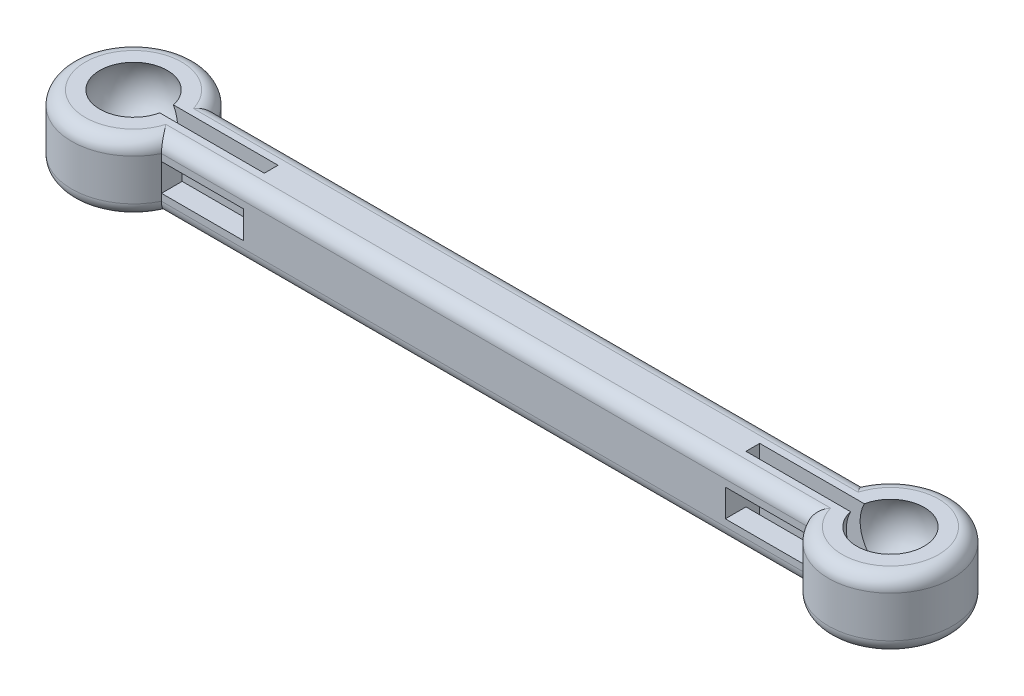
from build123d import *

# Parameters (mm, degrees)
BOSS_EXTRUDE1_DEPTH = 5
CUT_EXTRUDE1_REACH  = 34.699
CUT_EXTRUDE2_REACH  = 35.034
FILLET1_R           = 1
FILLET2_R           = 1


with BuildPart() as part:
    # Sketch1 → Boss-Extrude1 (new body)
    with BuildSketch(Plane(origin=(0, 0, 0), x_dir=(1, 0, 0), z_dir=(0, 1, 0))):
        with BuildLine():
            Line((-27.5, 2), (-27.5, -2))
            Line((-27.5, -2), (-23.46887112585063, -2))
            ThreePointArc((-23.468871125850672, -1.9999999999998734), (-23.11878556027716, -1.0271124734730797), (-23.000000000000007, -1.1e-15))
            ThreePointArc((-23.000000000000007, 0), (-23.11878556027716, 1.0271124734730805), (-23.468871125850672, 1.9999999999998725))
            Line((-23.46887112585063, 2), (-27.5, 2))
        make_face()
        with BuildLine():
            Line((-23.46887112585063, -2), (-27.5, -2))
            Line((-27.5, -2), (-27.5, 2))
            Line((-27.5, 2), (-23.46887112585063, 2))
            ThreePointArc((-23.468871125850672, 1.9999999999998725), (-31.999999999999993, 5.5e-16), (-23.468871125850672, -1.9999999999998734))
        make_face()
        with BuildLine():
            ThreePointArc((-23.000000000000007, -1.1e-15), (-23.11878556027716, -1.0271124734730797), (-23.468871125850672, -1.9999999999998734))
            Line((-23.46887112585063, -2), (23.46887112585071, -2))
            ThreePointArc((23.46887112585072, -1.9999999999999738), (23.000000000000007, 5.5e-16), (23.46887112585072, 1.9999999999999747))
            Line((23.46887112585071, 2), (-23.46887112585063, 2))
            ThreePointArc((-23.468871125850672, 1.9999999999998725), (-23.11878556027716, 1.0271124734730805), (-23.000000000000007, 0))
        make_face()
        with BuildLine():
            ThreePointArc((23.46887112585072, 1.9999999999999747), (23.000000000000007, 5.5e-16), (23.46887112585072, -1.9999999999999738))
            Line((23.46887112585071, -2), (27.5, -2))
            Line((27.5, -2), (27.5, 2))
            Line((27.5, 2), (23.46887112585071, 2))
        make_face()
        with BuildLine():
            Line((27.5, -2), (23.46887112585071, -2))
            ThreePointArc((23.46887112585072, -1.9999999999999738), (28.52711247347313, -4.381214439722833), (31.999999999999993, -1.1e-15))
            ThreePointArc((31.999999999999993, 0), (28.527112473473135, 4.381214439722831), (23.46887112585072, 1.9999999999999747))
            Line((23.46887112585071, 2), (27.5, 2))
            Line((27.5, 2), (27.5, -2))
        make_face()
    extrude(amount=BOSS_EXTRUDE1_DEPTH)

    # Cut-Sweep1: sweep along a path in Sketch2
    with BuildLine(Plane(origin=(0, 5, 0), x_dir=(1, 0, 0), z_dir=(0, 1, 0))) as cut_sweep1_path:
        CenterArc((-27.5, 0), 4.499999999999991, 0, 360)
    # 3DSketch1 → Cut-Sweep1 (sweep, cut)
    with BuildSketch(Plane(origin=(-27.5, 5, 0), x_dir=(0, -1, 0), z_dir=(-1, 0, 0))):
        with BuildLine():
            Line((0, 0), (-1.5000000000000004, 0))
            ThreePointArc((-1.5000000000000004, 0), (1.25, 2.75), (4, 0))
            Line((4, 0), (0, 0))
        make_face()
    cut_sweep1 = sweep(path=cut_sweep1_path.line, mode=Mode.SUBTRACT)

    # Mirror1: Cut-Sweep1 across plane
    add(cut_sweep1.mirror(Plane(origin=(0, 0, 0), x_dir=(0, 0, 1), z_dir=(1, 0, 0))), mode=Mode.SUBTRACT)

    # Cut-Extrude1: up to this face of the body (flat: up to its plane)
    cut_extrude1_end = Plane(part.part.faces().sort_by_distance((0, 5, -1.972e-06))[0])
    # Sketch3 → Cut-Extrude1 (cut, up to the picked face)
    with BuildSketch(Plane.XZ, mode=Mode.PRIVATE) as cut_extrude1_sk1:
        with BuildLine():
            ThreePointArc((-23.027864045000427, 0.49999999999997785), (-23.006971411314083, 0.2503879015666308), (-23.000000000000007, 0))
            Line((-23.000000000000007, 0), (-17.5, 0))
            Line((-17.5, 0), (-17.5, 0.5))
            Line((-17.5, 0.5), (-23.027864045000424, 0.5))
        make_face()
    cut_extrude1_tool1 = split(extrude(cut_extrude1_sk1.sketch, amount=-CUT_EXTRUDE1_REACH, mode=Mode.PRIVATE), bisect_by=cut_extrude1_end, keep=Keep.BOTH, mode=Mode.PRIVATE)
    # Sketch3 → Cut-Extrude1 (cut, up to the picked face)
    with BuildSketch(Plane.XZ, mode=Mode.PRIVATE) as cut_extrude1_sk2:
        with BuildLine():
            Line((-17.5, 0), (-23.000000000000007, 0))
            ThreePointArc((-23.000000000000007, -1.1e-15), (-23.006971411314083, -0.25038790156662954), (-23.027864045000427, -0.49999999999997824))
            Line((-23.027864045000424, -0.5), (-17.5, -0.5))
            Line((-17.5, -0.5), (-17.5, 0))
        make_face()
    cut_extrude1_tool2 = split(extrude(cut_extrude1_sk2.sketch, amount=-CUT_EXTRUDE1_REACH, mode=Mode.PRIVATE), bisect_by=cut_extrude1_end, keep=Keep.BOTH, mode=Mode.PRIVATE)
    # Sketch3 → Cut-Extrude1 (cut, up to the picked face)
    with BuildSketch(Plane.XZ, mode=Mode.PRIVATE) as cut_extrude1_sk3:
        with BuildLine():
            Line((-27.5, 0.5), (-27.5, 0))
            Line((-27.5, 0), (-23.000000000000007, 0))
            ThreePointArc((-23.000000000000007, 0), (-23.006971411314083, 0.2503879015666308), (-23.027864045000427, 0.49999999999997785))
            Line((-23.027864045000424, 0.5), (-27.5, 0.5))
        make_face()
    cut_extrude1_tool3 = split(extrude(cut_extrude1_sk3.sketch, amount=-CUT_EXTRUDE1_REACH, mode=Mode.PRIVATE), bisect_by=cut_extrude1_end, keep=Keep.BOTH, mode=Mode.PRIVATE)
    # Sketch3 → Cut-Extrude1 (cut, up to the picked face)
    with BuildSketch(Plane.XZ, mode=Mode.PRIVATE) as cut_extrude1_sk4:
        with BuildLine():
            Line((-23.000000000000007, 0), (-27.5, 0))
            Line((-27.5, 0), (-27.5, -0.5))
            Line((-27.5, -0.5), (-23.027864045000424, -0.5))
            ThreePointArc((-23.027864045000427, -0.49999999999997824), (-23.006971411314083, -0.25038790156662954), (-23.000000000000007, -1.1e-15))
        make_face()
    cut_extrude1_tool4 = split(extrude(cut_extrude1_sk4.sketch, amount=-CUT_EXTRUDE1_REACH, mode=Mode.PRIVATE), bisect_by=cut_extrude1_end, keep=Keep.BOTH, mode=Mode.PRIVATE)
    cut_extrude1_1 = cut_extrude1_tool1.solids().sort_by(Axis((-20.254644, 0, 0.250211), (0, 1, 0)))[0]
    add(cut_extrude1_1, mode=Mode.SUBTRACT)
    cut_extrude1_2 = cut_extrude1_tool2.solids().sort_by(Axis((-20.254644, 0, -0.250211), (0, 1, 0)))[0]
    add(cut_extrude1_2, mode=Mode.SUBTRACT)
    cut_extrude1_3 = cut_extrude1_tool3.solids().sort_by(Axis((-25.254631, 0, 0.249742), (0, 1, 0)))[0]
    add(cut_extrude1_3, mode=Mode.SUBTRACT)
    cut_extrude1_4 = cut_extrude1_tool4.solids().sort_by(Axis((-25.254631, 0, -0.249742), (0, 1, 0)))[0]
    add(cut_extrude1_4, mode=Mode.SUBTRACT)
    cut_extrude1 = cut_extrude1_1 + cut_extrude1_2 + cut_extrude1_3 + cut_extrude1_4  # Cut-Extrude1 as one shape, for the pattern or mirror that repeats it

    # Mirror2: Cut-Extrude1 across plane
    add(cut_extrude1.mirror(Plane(origin=(0, 0, 0), x_dir=(0, 0, 1), z_dir=(1, 0, 0))), mode=Mode.SUBTRACT)

    # Cut-Extrude2: up to this face of the body (flat: up to its plane)
    cut_extrude2_end = Plane(part.part.faces().sort_by_distance((0, 2.5, 2))[0])
    # Sketch4 → Cut-Extrude2 (cut, up to the picked face)
    with BuildSketch(Plane(origin=(0, 0, -2), x_dir=(-1, 0, 0), z_dir=(0, 0, -1)), mode=Mode.PRIVATE) as cut_extrude2_sk1:
        Polygon((17.499999999999996, 1.5000000000000016), (21.678209788095515, 1.5000000000000016), (19.290661337755218, 3.500000000000003), (17.499999999999996, 3.5000000000000018), align=None)
    cut_extrude2_tool1 = split(extrude(cut_extrude2_sk1.sketch, amount=-CUT_EXTRUDE2_REACH, mode=Mode.PRIVATE), bisect_by=cut_extrude2_end, keep=Keep.BOTH, mode=Mode.PRIVATE)
    # Sketch4 → Cut-Extrude2 (cut, up to the picked face)
    with BuildSketch(Plane(origin=(0, 0, -2), x_dir=(-1, 0, 0), z_dir=(0, 0, -1)), mode=Mode.PRIVATE) as cut_extrude2_sk2:
        Polygon((19.290661337755218, 3.500000000000003), (21.678209788095515, 1.5000000000000009), (23.468871125850736, 1.5000000000000016), (23.468871125850736, 3.5000000000000018), align=None)
    cut_extrude2_tool2 = split(extrude(cut_extrude2_sk2.sketch, amount=-CUT_EXTRUDE2_REACH, mode=Mode.PRIVATE), bisect_by=cut_extrude2_end, keep=Keep.BOTH, mode=Mode.PRIVATE)
    cut_extrude2_1 = cut_extrude2_tool1.solids().sort_by(Axis((-19.071803, 2.366667, -2), (0, 0, 1)))[0]
    add(cut_extrude2_1, mode=Mode.SUBTRACT)
    cut_extrude2_2 = cut_extrude2_tool2.solids().sort_by(Axis((-21.897068, 2.633333, -2), (0, 0, 1)))[0]
    add(cut_extrude2_2, mode=Mode.SUBTRACT)
    cut_extrude2 = cut_extrude2_1 + cut_extrude2_2  # Cut-Extrude2 as one shape, for the pattern or mirror that repeats it

    # Mirror3: Cut-Extrude2 across plane
    add(cut_extrude2.mirror(Plane(origin=(0, 0, 0), x_dir=(0, 0, 1), z_dir=(1, 0, 0))), mode=Mode.SUBTRACT)

    # Fillet1
    fillet1_edges = [part.edges().sort_by_distance(p)[0] for p in [
        (2.842e-14, 5, 1.9999999999999656),
        (31.999999999999993, 5, 0),
        (3.197e-14, 5, -1.9999999999999656),
        (-32.00000000000023, 5, 5.912e-14),
    ]]
    fillet(fillet1_edges, radius=FILLET1_R)

    # Fillet2
    fillet2_edges = [part.edges().sort_by_distance(p)[0] for p in [
        (3.197e-14, 0, -1.9999999999999656),
        (31.999999999999993, 0, 4.44e-15),
        (2.842e-14, 0, 1.9999999999999656),
        (-32.00000000000025, 0, -6.573e-14),
    ]]
    fillet(fillet2_edges, radius=FILLET2_R)


solid = part.part
